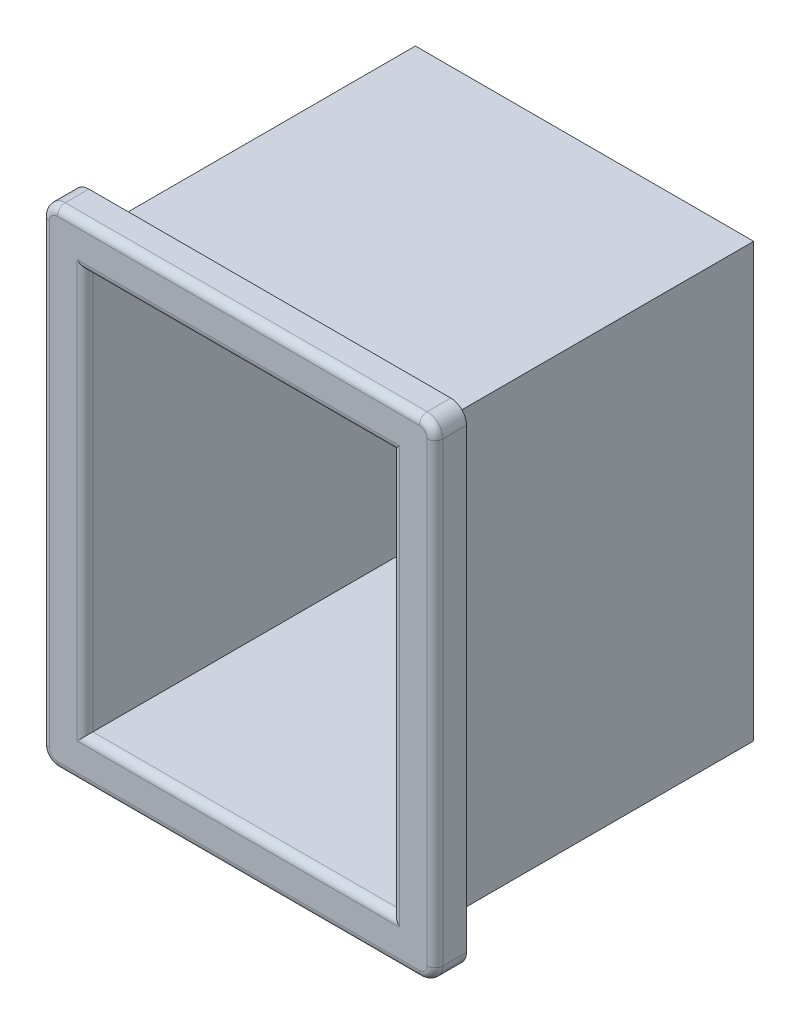
from build123d import *

# Parameters (mm, degrees)
SKETCH1_W           = 21.5
SKETCH1_H           = 27.5
BOSS_EXTRUDE1_DEPTH = 20
SKETCH2_W           = 25
SKETCH2_H           = 31
BOSS_EXTRUDE2_DEPTH = 2
SKETCH3_W           = 19.5
SKETCH3_H           = 25.5
CUT_EXTRUDE1_DEPTH  = 21
FILLET1_R           = 1
FILLET2_R           = 0.5


with BuildPart() as part:
    # Sketch1 → Boss-Extrude1 (new body)
    with BuildSketch(Plane.XY):
        Rectangle(SKETCH1_W, SKETCH1_H)
    extrude(amount=BOSS_EXTRUDE1_DEPTH)

    # Sketch2 → Boss-Extrude2 (add)
    with BuildSketch(Plane.XY.offset(20)):
        Rectangle(SKETCH2_W, SKETCH2_H)
    extrude(amount=BOSS_EXTRUDE2_DEPTH)

    # Sketch3 → Cut-Extrude1 (cut)
    with BuildSketch(Plane.XY.offset(22)):
        Rectangle(SKETCH3_W, SKETCH3_H)
    extrude(amount=-CUT_EXTRUDE1_DEPTH, mode=Mode.SUBTRACT)

    # Fillet1
    fillet1_edges = [part.edges().sort_by_distance(p)[0] for p in [
        (12.5, -15.5, 21),
        (12.5, 15.5, 21),
        (-12.5, 15.5, 21),
        (-12.5, -15.5, 21),
    ]]
    fillet(fillet1_edges, radius=FILLET1_R)

    # Fillet2
    fillet2_edges = [part.edges().sort_by_distance(p)[0] for p in [
        (9.75, 0, 22),
        (0, 12.75, 22),
        (-9.75, 0, 22),
        (0, -12.75, 22),
        (0, -15.5, 22),
        (-12.5, 0, 22),
        (12.5, 0, 22),
        (0, 15.5, 22),
        (12.207106781, 15.207106781, 22),
        (-12.207106781, 15.207106781, 22),
        (12.207106781, -15.207106781, 22),
        (-12.207106781, -15.207106781, 22),
    ]]
    fillet(fillet2_edges, radius=FILLET2_R)


solid = part.part
